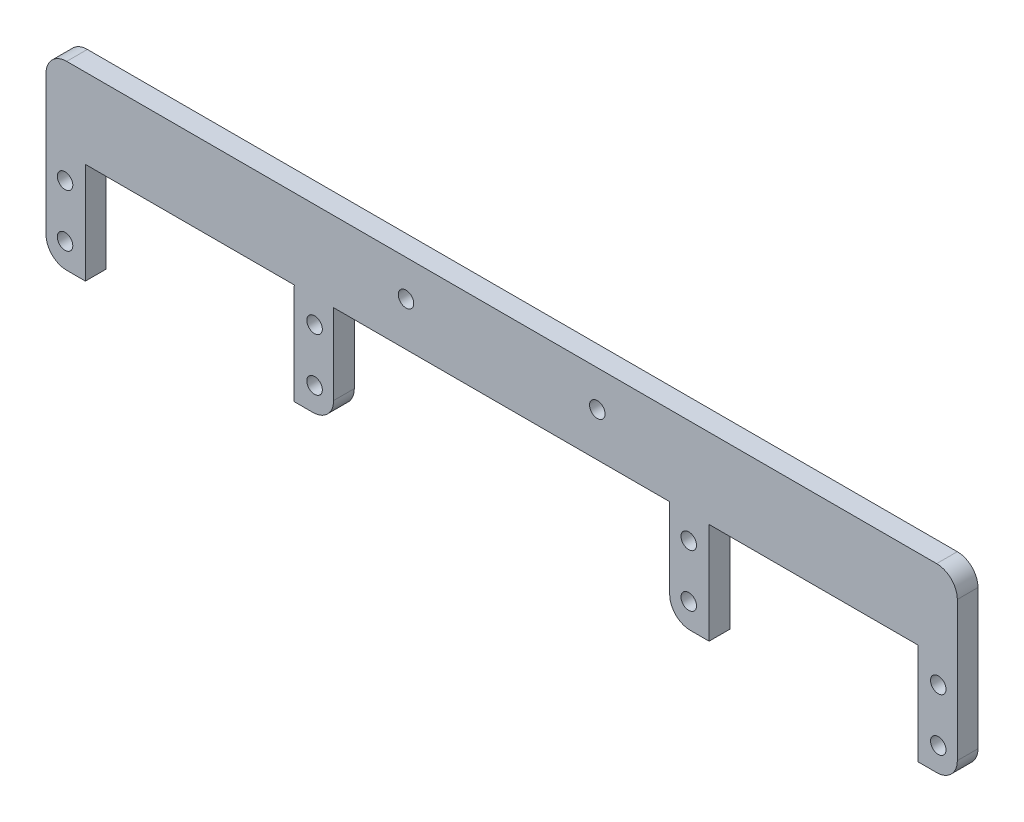
from build123d import *

# Parameters (mm, degrees)
BOSS_EXTRUDE2_DEPTH = 4
FILLET1_R           = 4
SKETCH6_R           = 1.5
CUT_EXTRUDE1_DEPTH  = 4
SKETCH3_R           = 1.5
CUT_EXTRUDE2_DEPTH  = 4


with BuildPart() as part:
    # Sketch2 → Boss-Extrude2 (new body)
    with BuildSketch(Plane.XY):
        Polygon((-87.081093968, -2.634474623), (-87.081093968, 16.923525377), (-46.695093968, 16.923525377), (-46.695093968, -2.634474623), (-39.075093968, -2.634474623), (-39.075093968, 32.365525377), (-67.081093968, 32.365525377), (-74.701093968, 32.365525377), (-159.701093968, 32.365525377), (-167.321093968, 32.365525377), (-215.327093968, 32.365525377), (-215.327093968, -2.634474623), (-207.707093968, -2.634474623), (-207.707093968, 16.923525377), (-167.321093968, 16.923525377), (-167.231910297, 16.736340115), (-167.321093968, 16.736752562), (-167.321093968, -2.634474623), (-159.701093968, -2.634474623), (-159.701093968, 16.923525377), (-94.701093968, 16.923525377), (-94.701093968, -2.634474623), align=None)
    extrude(amount=BOSS_EXTRUDE2_DEPTH)

    # Fillet1
    fillet1_edges = [part.edges().sort_by_distance(p)[0] for p in [
        (-39.075093968, 32.365525377, 2),
        (-39.075093968, -2.634474623, 2),
        (-94.701093968, -2.634474623, 2),
        (-159.701093968, -2.634474623, 2),
        (-215.327093968, -2.634474623, 2),
        (-215.327093968, 32.365525377, 2),
    ]]
    fillet(fillet1_edges, radius=FILLET1_R)

    # Sketch6 → Cut-Extrude1 (cut)
    with BuildSketch(Plane.XY.offset(4)):
        with Locations((-211.644093968, 12.224525377)):
            Circle(SKETCH6_R)
        with Locations((-163.384093968, 12.224525377)):
            Circle(SKETCH6_R)
        with Locations((-163.384093968, 2.064525377)):
            Circle(SKETCH6_R)
        with Locations((-211.644093968, 2.064525377)):
            Circle(SKETCH6_R)
        with Locations((-91.018093968, 12.224525377)):
            Circle(SKETCH6_R)
        with Locations((-42.758093968, 12.224525377)):
            Circle(SKETCH6_R)
        with Locations((-42.758093968, 2.064525377)):
            Circle(SKETCH6_R)
        with Locations((-91.018093968, 2.064525377)):
            Circle(SKETCH6_R)
    extrude(amount=-CUT_EXTRUDE1_DEPTH, mode=Mode.SUBTRACT)

    # Sketch3 → Cut-Extrude2 (cut)
    with BuildSketch(Plane.XY.offset(4)):
        with Locations((-145.701093968, 25.365525377)):
            Circle(SKETCH3_R)
        with Locations((-108.701093968, 25.365525377)):
            Circle(SKETCH3_R)
    extrude(amount=-CUT_EXTRUDE2_DEPTH, mode=Mode.SUBTRACT)


solid = part.part
